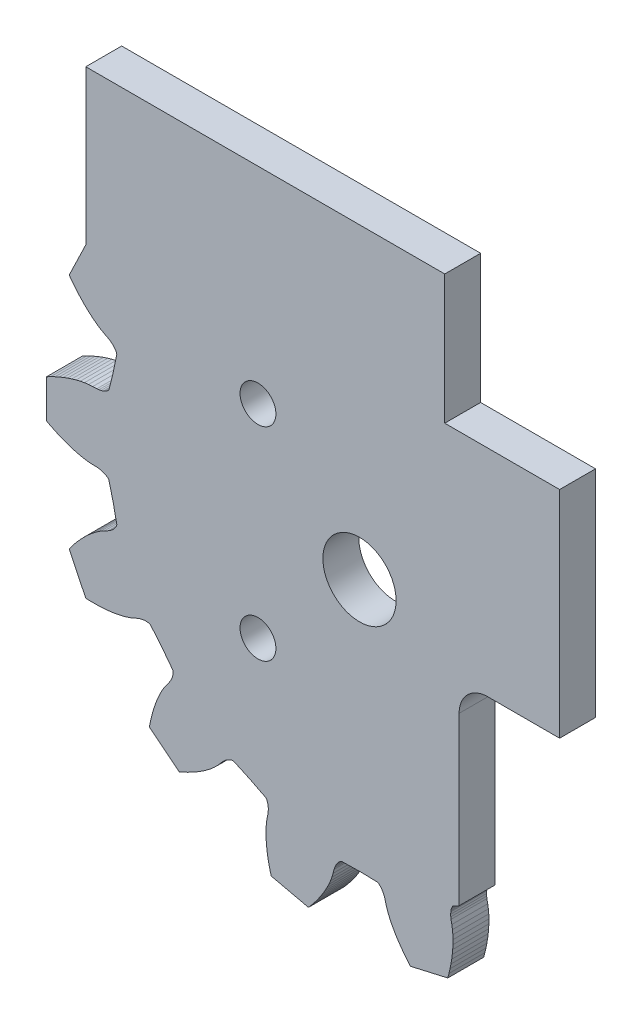
from build123d import *

# Parameters (mm, degrees)
SKETCH1_R                             = 3.2385
MAIN_GEAR_BODY_DEPTH                  = 3.175
BUILDUP_TO_MEET_BOTTOM_PLATE_DEPTH    = 3.175
SKETCH3_W                             = 29.96848222
SKETCH3_H                             = 58.010526443
CUT_TO_MATE_TO_FACE_BACKPLATE_DEPTH   = 4.175
SKETCH4_W                             = 8.89
SKETCH4_H                             = 25.4
SKETCH4_W_2                           = 10.16
SKETCH4_H_2                           = 11.43
CUT_FOR_ANGLE_BRACKET_CLEARANCE_DEPTH = 4.175
SKETCH5_R                             = 1.5875
CUT_FOR_SCREWS_DEPTH                  = 4.175
FILLET1_R                             = 2.54


with BuildPart() as part:
    # Sketch1 → main gear body (new body)
    with BuildSketch(Plane.XY):
        Polygon((49.520094, 32.708088), (49.907444, 31.160212), (50.014124, 31.055056), (50.115724, 30.981904), (50.21453, 30.92577), (50.311558, 30.881066), (50.407316, 30.844998), (50.596038, 30.791404), (50.781966, 30.756606), (50.965862, 30.736032), (51.32959, 30.72638), (51.694588, 30.702758), (52.062888, 30.653228), (52.43322, 30.582362), (52.805076, 30.4927), (53.177948, 30.385766), (53.551582, 30.262576), (53.925724, 30.124146), (54.30012, 29.97073), (54.674262, 29.80309), (55.047896, 29.621226), (55.420768, 29.426154), (55.420768, 26.046176), (55.047896, 25.851104), (54.674262, 25.66924), (54.30012, 25.5016), (53.925724, 25.348184), (53.551582, 25.209754), (53.177948, 25.086564), (52.805076, 24.97963), (52.43322, 24.889968), (52.062888, 24.819102), (51.694588, 24.769318), (51.32959, 24.74595), (50.965862, 24.736298), (50.781966, 24.715724), (50.596038, 24.680926), (50.407316, 24.627332), (50.311558, 24.591264), (50.21453, 24.54656), (50.115724, 24.490426), (50.014124, 24.417274), (49.907444, 24.312118), (49.520094, 22.764242), (49.19726, 21.20138), (49.24806, 21.06041), (49.30775, 20.950174), (49.37252, 20.856956), (49.440592, 20.77466), (49.51095, 20.700492), (49.657762, 20.57019), (49.810162, 20.458176), (49.96688, 20.360132), (50.290476, 20.193508), (50.609246, 20.01393), (50.91938, 19.80946), (51.222402, 19.584924), (51.518312, 19.342862), (51.808126, 19.084544), (52.091336, 18.811494), (52.368196, 18.52422), (52.63896, 18.223738), (52.903374, 17.910302), (53.161184, 17.58442), (53.41239, 17.246854), (51.946048, 14.201648), (51.52517, 14.187678), (51.10988, 14.186154), (50.699924, 14.19733), (50.296064, 14.22146), (49.899062, 14.259052), (49.508918, 14.310106), (49.126394, 14.375638), (48.752506, 14.456156), (48.388016, 14.55293), (48.034956, 14.667992), (47.695612, 14.805406), (47.363634, 14.95425), (47.189136, 15.015718), (47.00651, 15.064994), (46.81347, 15.098522), (46.711362, 15.107412), (46.604682, 15.109444), (46.491398, 15.101824), (46.367954, 15.079726), (46.225968, 15.031466), (45.20565, 13.8049), (44.23664, 12.536932), (44.221146, 12.387834), (44.227242, 12.262612), (44.245022, 12.150598), (44.270676, 12.046712), (44.301918, 11.94943), (44.37761, 11.768582), (44.466256, 11.60145), (44.565062, 11.444986), (44.78401, 11.15441), (44.99356, 10.854436), (45.184314, 10.535666), (45.359828, 10.20191), (45.521372, 9.8552), (45.67047, 9.49706), (45.807122, 9.127998), (45.93209, 8.74903), (46.045628, 8.360918), (46.147736, 7.963662), (46.238668, 7.558278), (46.318424, 7.14502), (43.676062, 5.037836), (43.290744, 5.207508), (42.91584, 5.386578), (42.551604, 5.574538), (42.19829, 5.771388), (41.85666, 5.977636), (41.527222, 6.193028), (41.211246, 6.417818), (40.90924, 6.652768), (40.622982, 6.897878), (40.354504, 7.154926), (40.108632, 7.425944), (39.87419, 7.704074), (39.743634, 7.835138), (39.600378, 7.958836), (39.440866, 8.072882), (39.352982, 8.124952), (39.257478, 8.173212), (39.152068, 8.215376), (39.031418, 8.249158), (38.882574, 8.267192), (37.430964, 7.60476), (36.008056, 6.882892), (35.929316, 6.75513), (35.880294, 6.639814), (35.847782, 6.531102), (35.825684, 6.426454), (35.811714, 6.325108), (35.801554, 6.129274), (35.80892, 5.940298), (35.830002, 5.756402), (35.901376, 5.399786), (35.959796, 5.038598), (35.993324, 4.66852), (36.006532, 4.291838), (36.00196, 3.909314), (35.980624, 3.521964), (35.943794, 3.130042), (35.891978, 2.734564), (35.825684, 2.33553), (35.74542, 1.933448), (35.65144, 1.528826), (35.543998, 1.121664), (32.24911, 0.36957), (31.975806, 0.68961), (31.715456, 1.013714), (31.468822, 1.34112), (31.235904, 1.671828), (31.017464, 2.005838), (30.814264, 2.342642), (30.627066, 2.682494), (30.456886, 3.02514), (30.305502, 3.370326), (30.1752, 3.718052), (30.07106, 4.06908), (29.980636, 4.421378), (29.919676, 4.59613), (29.844492, 4.769612), (29.750258, 4.94157), (29.693616, 5.026914), (29.628338, 5.111496), (29.551884, 5.195316), (29.45765, 5.27812), (29.331412, 5.358892), (27.736038, 5.391912), (26.140918, 5.358892), (26.01468, 5.27812), (25.920446, 5.195316), (25.843738, 5.111496), (25.778714, 5.026914), (25.722072, 4.94157), (25.627838, 4.769612), (25.552654, 4.59613), (25.491694, 4.421378), (25.40127, 4.06908), (25.29713, 3.718052), (25.166828, 3.370326), (25.015444, 3.02514), (24.845264, 2.682494), (24.658066, 2.342642), (24.454866, 2.005838), (24.236426, 1.671828), (24.003508, 1.34112), (23.756874, 1.013714), (23.496524, 0.68961), (23.22322, 0.36957), (19.928332, 1.121664), (19.82089, 1.528826), (19.72691, 1.933448), (19.646646, 2.33553), (19.580352, 2.734564), (19.528536, 3.130042), (19.491706, 3.521964), (19.47037, 3.909314), (19.465798, 4.291838), (19.479006, 4.66852), (19.512534, 5.038598), (19.570954, 5.399786), (19.642328, 5.756402), (19.66341, 5.940298), (19.670776, 6.129274), (19.660616, 6.325108), (19.646646, 6.426454), (19.624548, 6.531102), (19.592036, 6.639814), (19.543014, 6.75513), (19.464274, 6.882892), (18.041366, 7.60476), (16.589756, 8.267192), (16.440912, 8.249158), (16.320262, 8.215376), (16.214852, 8.173212), (16.119348, 8.124952), (16.031464, 8.072882), (15.871952, 7.958836), (15.728696, 7.835138), (15.59814, 7.704074), (15.363698, 7.425944), (15.117826, 7.154926), (14.849348, 6.897878), (14.56309, 6.652768), (14.261084, 6.417818), (13.945108, 6.193028), (13.61567, 5.977636), (13.27404, 5.771388), (12.920726, 5.574538), (12.55649, 5.386578), (12.181586, 5.207508), (11.796268, 5.037836), (9.153906, 7.14502), (9.233662, 7.558278), (9.324594, 7.963662), (9.426702, 8.360918), (9.54024, 8.74903), (9.665208, 9.127998), (9.80186, 9.49706), (9.950958, 9.8552), (10.112502, 10.20191), (10.288016, 10.535666), (10.47877, 10.854436), (10.68832, 11.15441), (10.907268, 11.444986), (11.00582, 11.60145), (11.09472, 11.768582), (11.170412, 11.94943), (11.201654, 12.046712), (11.227308, 12.150598), (11.245088, 12.262612), (11.251184, 12.387834), (11.235436, 12.536932), (10.26668, 13.8049), (9.246362, 15.031466), (9.104376, 15.079726), (8.980932, 15.101824), (8.867648, 15.109444), (8.760968, 15.107412), (8.65886, 15.098522), (8.46582, 15.064994), (8.283194, 15.015718), (8.108696, 14.95425), (7.776718, 14.805406), (7.437374, 14.667992), (7.084314, 14.55293), (6.719824, 14.456156), (6.345936, 14.375638), (5.963412, 14.310106), (5.573268, 14.259052), (5.176266, 14.22146), (4.772406, 14.19733), (4.36245, 14.186154), (3.94716, 14.187678), (3.526282, 14.201648), (2.05994, 17.246854), (2.311146, 17.58442), (2.568956, 17.910302), (2.83337, 18.223738), (3.104134, 18.52422), (3.380994, 18.811494), (3.664204, 19.084544), (3.954018, 19.342862), (4.249928, 19.584924), (4.55295, 19.80946), (4.863084, 20.01393), (5.181854, 20.193508), (5.50545, 20.360132), (5.662168, 20.458176), (5.814568, 20.57019), (5.96138, 20.700492), (6.031738, 20.77466), (6.09981, 20.856956), (6.16458, 20.950174), (6.22427, 21.06041), (6.274816, 21.20138), (5.952236, 22.764242), (5.564886, 24.312118), (5.458206, 24.417274), (5.356606, 24.490426), (5.2578, 24.54656), (5.160772, 24.591264), (5.065014, 24.627332), (4.876292, 24.680926), (4.690364, 24.715724), (4.506468, 24.736298), (4.14274, 24.74595), (3.777742, 24.769318), (3.409442, 24.819102), (3.03911, 24.889968), (2.667254, 24.97963), (2.294382, 25.086564), (1.920748, 25.209754), (1.546606, 25.348184), (1.17221, 25.5016), (0.798068, 25.66924), (0.424434, 25.851104), (0.051562, 26.046176), (0.051562, 29.426154), (0.424434, 29.621226), (0.798068, 29.80309), (1.17221, 29.97073), (1.546606, 30.124146), (1.920748, 30.262576), (2.294382, 30.385766), (2.667254, 30.4927), (3.03911, 30.582362), (3.409442, 30.653228), (3.777742, 30.702758), (4.14274, 30.72638), (4.506468, 30.736032), (4.690364, 30.756606), (4.876292, 30.791404), (5.065014, 30.844998), (5.160772, 30.881066), (5.2578, 30.92577), (5.356606, 30.981904), (5.458206, 31.055056), (5.564886, 31.160212), (5.952236, 32.708088), (6.274816, 34.27095), (6.22427, 34.41192), (6.16458, 34.522156), (6.09981, 34.615374), (6.031738, 34.69767), (5.96138, 34.771838), (5.814568, 34.90214), (5.662168, 35.014154), (5.50545, 35.112198), (5.181854, 35.278822), (4.863084, 35.4584), (4.55295, 35.66287), (4.249928, 35.887406), (3.954018, 36.129468), (3.664204, 36.387786), (3.380994, 36.660836), (3.104134, 36.94811), (2.83337, 37.248592), (2.568956, 37.562028), (2.311146, 37.88791), (2.05994, 38.225476), (3.526282, 41.270682), (3.94716, 41.284652), (4.36245, 41.286176), (4.772406, 41.275), (5.176266, 41.25087), (5.573268, 41.213278), (5.963412, 41.162224), (6.345936, 41.096692), (6.719824, 41.016174), (7.084314, 40.9194), (7.437374, 40.804338), (7.776718, 40.666924), (8.108696, 40.51808), (8.283194, 40.456612), (8.46582, 40.407336), (8.65886, 40.373808), (8.760968, 40.364918), (8.867648, 40.362886), (8.980932, 40.370506), (9.104376, 40.392604), (9.246362, 40.440864), (10.26668, 41.66743), (11.235436, 42.935398), (11.251184, 43.084496), (11.245088, 43.209718), (11.227308, 43.321732), (11.201654, 43.425618), (11.170412, 43.5229), (11.09472, 43.703748), (11.00582, 43.87088), (10.907268, 44.027344), (10.68832, 44.31792), (10.47877, 44.617894), (10.288016, 44.936664), (10.112502, 45.27042), (9.950958, 45.61713), (9.80186, 45.97527), (9.665208, 46.344332), (9.54024, 46.7233), (9.426702, 47.111412), (9.324594, 47.508668), (9.233662, 47.914052), (9.153906, 48.32731), (11.796268, 50.434494), (12.181586, 50.264822), (12.55649, 50.085752), (12.920726, 49.897792), (13.27404, 49.700942), (13.61567, 49.494694), (13.945108, 49.279302), (14.261084, 49.054512), (14.56309, 48.819562), (14.849348, 48.574452), (15.117826, 48.317404), (15.363698, 48.046386), (15.59814, 47.768256), (15.728696, 47.637192), (15.871952, 47.513494), (16.031464, 47.399448), (16.119348, 47.347124), (16.214852, 47.299118), (16.320262, 47.256954), (16.440912, 47.223172), (16.589756, 47.205138), (18.041366, 47.86757), (19.464274, 48.589438), (19.543014, 48.7172), (19.592036, 48.832516), (19.624548, 48.941228), (19.646646, 49.045876), (19.660616, 49.147222), (19.670776, 49.343056), (19.66341, 49.532032), (19.642328, 49.715928), (19.570954, 50.072544), (19.512534, 50.433732), (19.479006, 50.80381), (19.465798, 51.180492), (19.47037, 51.563016), (19.491706, 51.950366), (19.528536, 52.342288), (19.580352, 52.737766), (19.82089, 52.737766), (20.372537713, 53.129688), (21.034433175, 53.466492), (21.492668494, 53.800502), (22.358224098, 54.13121), (23.22322, 54.13121), (23.756874, 54.13121), (24.003508, 54.13121), (24.236426, 53.800502), (24.454866, 53.466492), (24.658066, 53.129688), (24.845264, 52.789836), (25.015444, 52.44719), (25.166828, 52.102004), (25.29713, 51.754024), (25.40127, 51.40325), (25.491694, 51.050952), (25.552654, 50.8762), (25.627838, 50.702718), (25.722072, 50.53076), (25.778714, 50.445416), (25.843738, 50.360834), (25.920446, 50.277014), (26.01468, 50.19421), (26.140918, 50.113438), (27.736038, 50.080418), (29.331412, 50.113438), (29.45765, 50.19421), (29.551884, 50.277014), (29.628338, 50.360834), (29.693616, 50.445416), (29.750258, 50.53076), (29.844492, 50.702718), (29.919676, 50.8762), (29.980636, 51.050952), (30.07106, 51.40325), (30.1752, 51.754024), (30.305502, 52.102004), (30.456886, 52.44719), (30.627066, 52.789836), (30.814264, 53.129688), (31.017464, 53.466492), (31.235904, 53.800502), (31.468822, 54.13121), (31.975806, 53.800502), (32.795806377, 53.800502), (33.763192052, 53.800502), (34.628747656, 53.800502), (35.443388224, 53.61078489), (35.74542, 53.538882), (35.825684, 53.1368), (35.891978, 52.737766), (35.943794, 52.342288), (35.980624, 51.950366), (36.00196, 51.563016), (36.006532, 51.180492), (35.993324, 50.80381), (35.959796, 50.433732), (35.901376, 50.072544), (35.830002, 49.715928), (35.80892, 49.532032), (35.801554, 49.343056), (35.811714, 49.147222), (35.825684, 49.045876), (35.847782, 48.941228), (35.880294, 48.832516), (35.929316, 48.7172), (36.008056, 48.589438), (37.430964, 47.86757), (38.882574, 47.205138), (39.031418, 47.223172), (39.152068, 47.256954), (39.257478, 47.299118), (39.352982, 47.347124), (39.440866, 47.399448), (39.600378, 47.513494), (39.743634, 47.637192), (39.87419, 47.768256), (40.108632, 48.046386), (40.354504, 48.317404), (40.622982, 48.574452), (40.90924, 48.819562), (41.211246, 49.054512), (41.527222, 49.279302), (41.85666, 49.494694), (42.19829, 49.700942), (42.551604, 49.897792), (42.91584, 50.085752), (43.290744, 50.264822), (43.676062, 50.434494), (46.318424, 48.32731), (46.238668, 47.914052), (46.147736, 47.508668), (46.045628, 47.111412), (45.93209, 46.7233), (45.807122, 46.344332), (45.67047, 45.97527), (45.521372, 45.61713), (45.359828, 45.27042), (45.184314, 44.936664), (44.99356, 44.617894), (44.78401, 44.31792), (44.565062, 44.027344), (44.466256, 43.87088), (44.37761, 43.703748), (44.301918, 43.5229), (44.270676, 43.425618), (44.245022, 43.321732), (44.227242, 43.209718), (44.221146, 43.084496), (44.23664, 42.935398), (45.20565, 41.66743), (46.225968, 40.440864), (46.367954, 40.392604), (46.491398, 40.370506), (46.604682, 40.362886), (46.711362, 40.364918), (46.81347, 40.373808), (47.00651, 40.407336), (47.189136, 40.456612), (47.363634, 40.51808), (47.695612, 40.666924), (48.034956, 40.804338), (48.388016, 40.9194), (48.752506, 41.016174), (49.126394, 41.096692), (49.508918, 41.162224), (49.899062, 41.213278), (50.296064, 41.25087), (50.699924, 41.275), (51.10988, 41.286176), (51.52517, 41.284652), (51.946048, 41.270682), (53.41239, 38.225476), (53.161184, 37.88791), (52.903374, 37.562028), (52.63896, 37.248592), (52.368196, 36.94811), (52.091336, 36.660836), (51.808126, 36.387786), (51.518312, 36.129468), (51.222402, 35.887406), (50.91938, 35.66287), (50.609246, 35.4584), (50.290476, 35.278822), (49.96688, 35.112198), (49.810162, 35.014154), (49.657762, 34.90214), (49.51095, 34.771838), (49.440592, 34.69767), (49.37252, 34.615374), (49.30775, 34.522156), (49.24806, 34.41192), (49.19726, 34.27095), align=None)
        with Locations((27.736038, 27.736038)):
            Circle(SKETCH1_R, mode=Mode.SUBTRACT)
    extrude(amount=MAIN_GEAR_BODY_DEPTH)

    # Sketch2 → buildup to meet bottom plate (add)
    with BuildSketch(Plane.XY.offset(3.175)):
        Polygon((3.526282, 41.270682), (3.526282, 54.914038), (46.225968, 54.914038), (46.225968, 15.031466), (34.609948438, 32.843973929), (21.58017356, 32.843973929), align=None)
    extrude(amount=-BUILDUP_TO_MEET_BOTTOM_PLATE_DEPTH)

    # Sketch3 → cut to mate to face backplate (cut, through all)
    with BuildSketch(Plane.XY.offset(3.175)):
        with Locations((60.42052311, 25.908774779)):
            Rectangle(SKETCH3_W, SKETCH3_H)
    extrude(amount=-CUT_TO_MATE_TO_FACE_BACKPLATE_DEPTH, mode=Mode.SUBTRACT)

    # Sketch4 → cut for angle bracket clearance (cut, through all)
    with BuildSketch(Plane.XY.offset(3.175)):
        with Locations((40.991282, 11.734038)):
            Rectangle(SKETCH4_W, SKETCH4_H)
        with Locations((40.356282, 49.199038)):
            Rectangle(SKETCH4_W_2, SKETCH4_H_2)
    extrude(amount=-CUT_FOR_ANGLE_BRACKET_CLEARANCE_DEPTH, mode=Mode.SUBTRACT)

    # Sketch5 → cut for screws (cut, through all)
    with BuildSketch(Plane.XY.offset(3.175)):
        with Locations((18.755781879, 36.716294121)):
            Circle(SKETCH5_R)
        with Locations((18.755781879, 18.755781879)):
            Circle(SKETCH5_R)
    extrude(amount=-CUT_FOR_SCREWS_DEPTH, mode=Mode.SUBTRACT)

    # Fillet1
    fillet1_edges = [part.edges().sort_by_distance(p)[0] for p in [
        (36.546282, 24.434038, 1.5875),
    ]]
    fillet(fillet1_edges, radius=FILLET1_R)


solid = part.part
